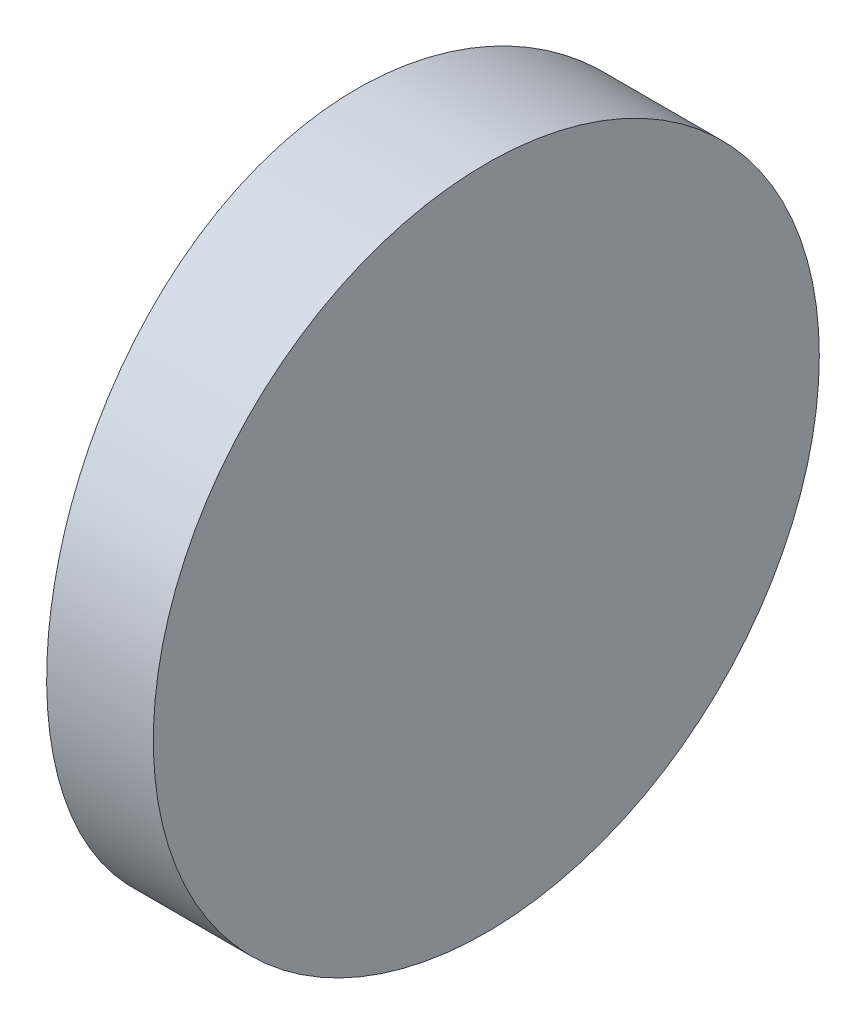
from build123d import *

# Parameters (mm, degrees)
EXTRUDE_1_DEPTH     = 12.5
CUT_EXTRUDE_8_DEPTH = 12.7


with BuildPart() as part:
    # 草图1 → 凸台-拉伸1 (new body)
    with BuildSketch(Plane(origin=(0, 0, 0), x_dir=(1, 0, 0), z_dir=(0, 1, 0))):
        with BuildLine():
            Line((-41.066816756, 6.25), (-39.064795665, 6.25))
            Line((-39.064795665, 6.25), (-39.064795665, -6.25))
            Line((-39.064795665, -6.25), (-41.066816756, -6.25))
            ThreePointArc((-41.066816756, -6.25), (-41.494795665, 0), (-41.066816756, 6.25))
        make_face()
    extrude(amount=EXTRUDE_1_DEPTH)

    # 草图2 → 切除-拉伸8 (cut)
    with BuildSketch(Plane(origin=(-39.064795665, 0, 0), x_dir=(0, 0, -1), z_dir=(1, 0, 0))):
        with BuildLine():
            Line((-6.25, 12.5), (-6.25, 6.250000002))
            ThreePointArc((-6.25, 6.250000002), (-4.419417382, 10.669417383), (0, 12.5))
            Line((0, 12.5), (-6.25, 12.5))
        make_face()
        with BuildLine():
            ThreePointArc((0, 12.5), (4.419417382, 10.669417382), (6.25, 6.25))
            Line((6.25, 6.25), (6.25, 12.5))
            Line((6.25, 12.5), (0, 12.5))
        make_face()
        with BuildLine():
            ThreePointArc((6.25, 6.25), (4.419417382, 1.830582618), (0, 0))
            Line((0, 0), (6.25, 0))
            Line((6.25, 0), (6.25, 6.25))
        make_face()
        with BuildLine():
            Line((-6.25, 6.250000002), (-6.25, 0))
            Line((-6.25, 0), (0, 0))
            ThreePointArc((0, 0), (-4.419417383, 1.830582618), (-6.25, 6.250000002))
        make_face()
    extrude(amount=-CUT_EXTRUDE_8_DEPTH, mode=Mode.SUBTRACT)


solid = part.part
